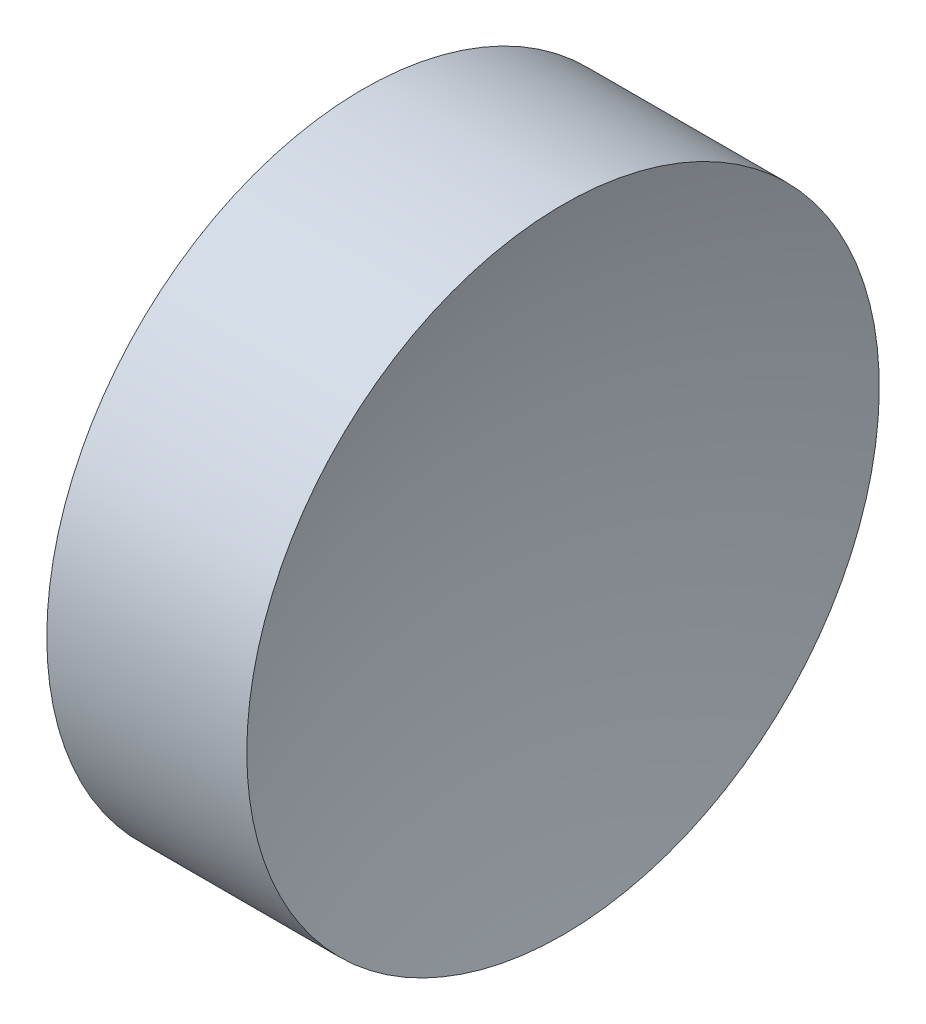
from build123d import *


with BuildPart() as part:
    # 草图1 → 旋转1 (revolve)
    with BuildSketch(Plane.XY, mode=Mode.PRIVATE) as revolve_1_sk:
        with BuildLine():
            Line((22.309268833, 13.031126091), (22.309268833, 16.181126091))
            Line((22.309268833, 16.181126091), (24.301260904, 16.181126091))
            ThreePointArc((24.301260904, 16.181126091), (23.933007962, 14.625221148), (23.809268833, 13.031126091))
            Line((23.809268833, 13.031126091), (22.309268833, 13.031126091))
        make_face()
    revolve(revolve_1_sk.sketch.rotate(Axis((20.684030635, 13.031126091, 0), (1, 0, 0)), 180), axis=Axis((20.684030635, 13.031126091, 0), (1, 0, 0)))  # turned: the seam where the file's is


solid = part.part
